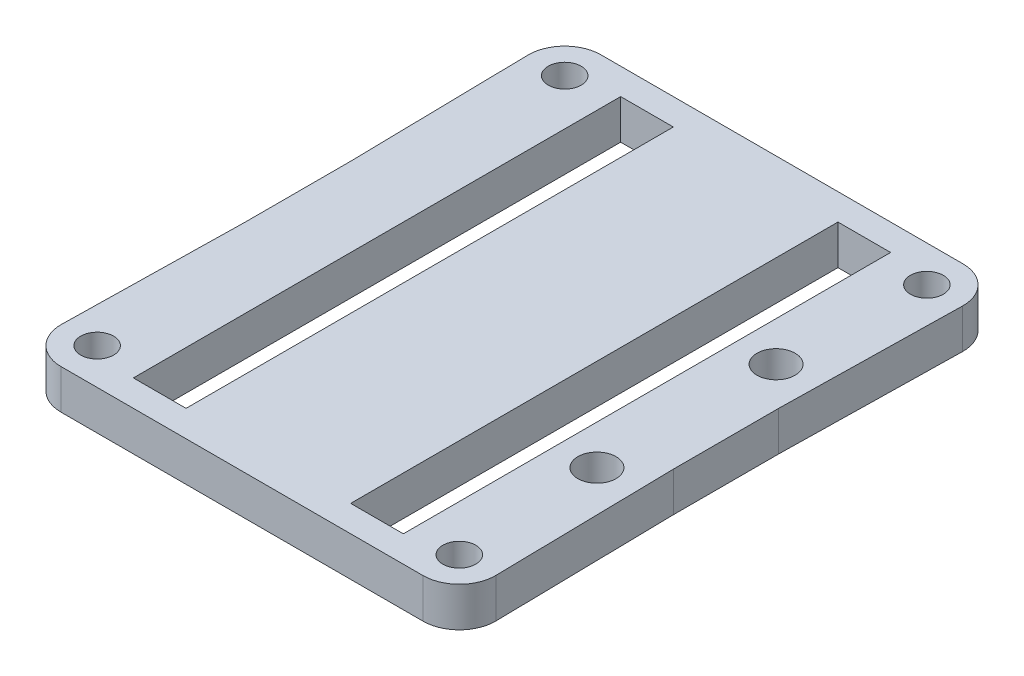
from build123d import *

# Parameters (mm, degrees)
SKETCH1_R              = 1.25
SKETCH1_W              = 12.5
SKETCH1_H              = 37
BOSS_EXTRUDE1_DEPTH    = 3
M2_5_CLEARANCE_HOLE1_D = 2.9


with BuildPart() as part:
    # Sketch1 → Boss-Extrude1 (new body)
    with BuildSketch(Plane(origin=(0, 0, 0), x_dir=(1, 0, 0), z_dir=(0, 1, 0))):
        with BuildLine():
            Line((-16.25, -4), (-16.499543908, -17.699917074))
            ThreePointArc((-16.499543908, -17.699917074), (-15.712170743, -19.676755298), (-13.75, -20.5))
            Line((-13.75, -20.5), (13.75, -20.5))
            ThreePointArc((13.75, -20.5), (15.712170743, -19.676755298), (16.499543908, -17.699917074))
            Line((16.499543908, -17.699917074), (16.25, -4))
            Line((16.25, -4), (16.25, 0))
            Line((16.25, 0), (16.25, 4))
            Line((16.25, 4), (16.499543908, 17.699917074))
            ThreePointArc((16.499543908, 17.699917074), (15.712170743, 19.676755298), (13.75, 20.5))
            Line((13.75, 20.5), (-13.75, 20.5))
            ThreePointArc((-13.75, 20.5), (-15.712170743, 19.676755298), (-16.499543908, 17.699917074))
            Line((-16.499543908, 17.699917074), (-16.25, 4))
            Line((-16.25, 4), (-16.25, 0))
            Line((-16.25, 0), (-16.25, -4))
        make_face()
        with Locations((-13.75, -17.75)):
            Circle(SKETCH1_R, mode=Mode.SUBTRACT)
        with Locations((-13.75, 17.75)):
            Circle(SKETCH1_R, mode=Mode.SUBTRACT)
        with Locations((13.75, 17.75)):
            Circle(SKETCH1_R, mode=Mode.SUBTRACT)
        with Locations((13.75, -17.75)):
            Circle(SKETCH1_R, mode=Mode.SUBTRACT)
        Polygon((-6.25, 18.5), (-10.25, 18.5), (-10.25, -18.5), (-6.25, -18.5), (6.25, -18.5), (10.25, -18.5), (10.25, 18.5), (6.25, 18.5), align=None, mode=Mode.SUBTRACT)
        Rectangle(SKETCH1_W, SKETCH1_H)
    extrude(amount=BOSS_EXTRUDE1_DEPTH)

    # M2.5 Clearance Hole1 (through all)
    with Locations(Plane.XZ):
        with Locations((13.25, -6.8), (13.25, 6.8)):
            Hole(M2_5_CLEARANCE_HOLE1_D / 2)


solid = part.part
